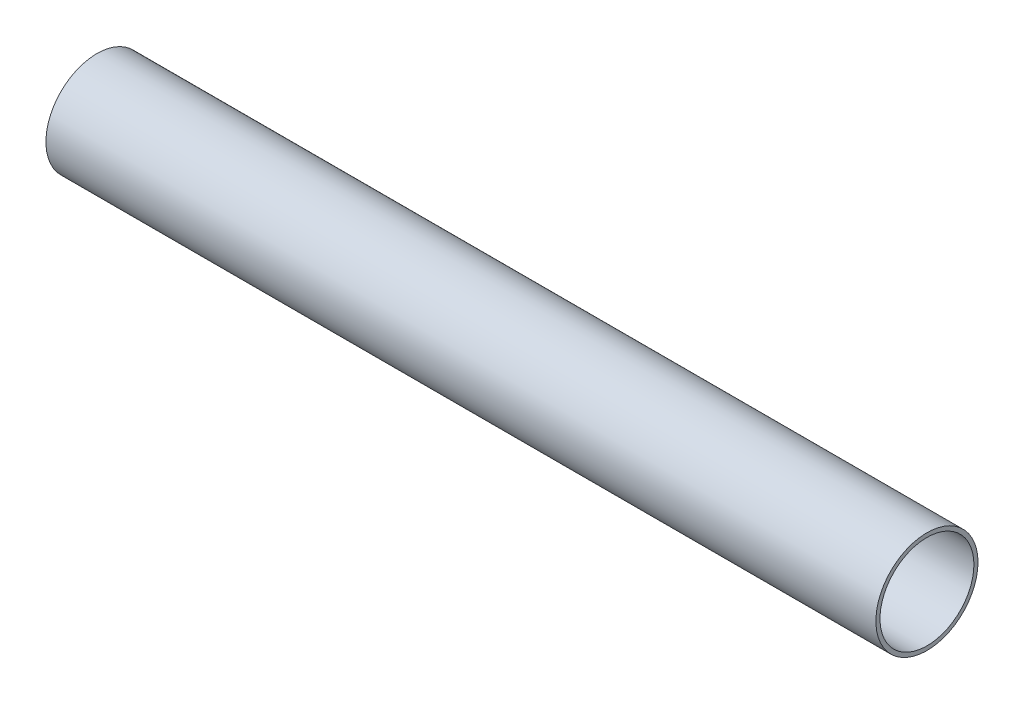
from build123d import *

# Parameters (mm, degrees)
SKETCH1_R           = 12.5
SKETCH1_R_2         = 11.5
BOSS_EXTRUDE1_DEPTH = 203.2


with BuildPart() as part:
    # Sketch1 → Boss-Extrude1 (new body)
    with BuildSketch(Plane(origin=(0, 0, 0), x_dir=(0, 0, -1), z_dir=(1, 0, 0))):
        Circle(SKETCH1_R)
        Circle(SKETCH1_R_2, mode=Mode.SUBTRACT)
    extrude(amount=BOSS_EXTRUDE1_DEPTH)


solid = part.part
